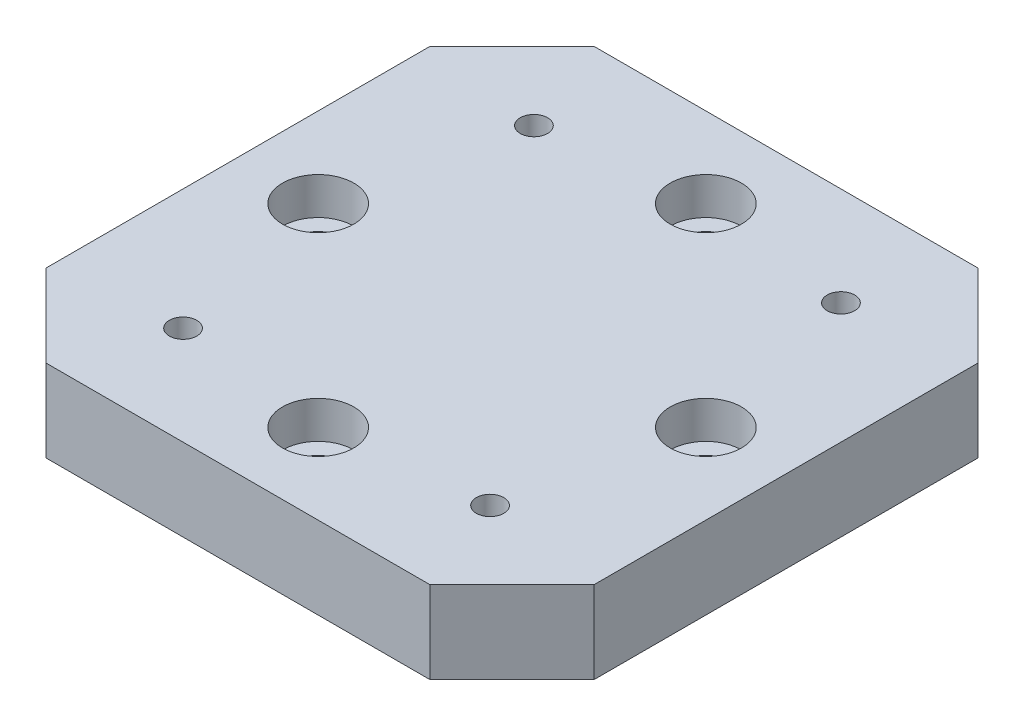
from build123d import *

# Parameters (mm, degrees)
SKETCH1_W                                           = 50
SKETCH1_H                                           = 50
BOSS_EXTRUDE1_DEPTH                                 = 7.5
M3_TAPPED_HOLE1_D                                   = 2.5
M3_TAPPED_HOLE1_DEPTH                               = 7.5
CBORE_FOR_M3_HEX_SOCKET_HEAD_CAP_SCREW1_D           = 3.4
CBORE_FOR_M3_HEX_SOCKET_HEAD_CAP_SCREW1_DEPTH       = 7.5
CBORE_FOR_M3_HEX_SOCKET_HEAD_CAP_SCREW1_CBORE_D     = 6.5
CBORE_FOR_M3_HEX_SOCKET_HEAD_CAP_SCREW1_CBORE_DEPTH = 3.4
CHAMFER1_SIZE                                       = 7.5


with BuildPart() as part:
    # Sketch1 → Boss-Extrude1 (new body)
    with BuildSketch(Plane(origin=(0, 0, 0), x_dir=(1, 0, 0), z_dir=(0, 1, 0))):
        Rectangle(SKETCH1_W, SKETCH1_H)
    extrude(amount=BOSS_EXTRUDE1_DEPTH)

    # M3 Tapped Hole1
    with Locations(Plane(origin=(0, 7.5, 0), x_dir=(1, 0, 0), z_dir=(0, 1, 0))):
        with Locations((-14, -16), (-14, 16), (14, 16), (14, -16)):
            Hole(M3_TAPPED_HOLE1_D / 2, depth=M3_TAPPED_HOLE1_DEPTH)

    # CBORE for M3 Hex Socket Head Cap Screw1
    with Locations(Plane(origin=(0, 7.5, 0), x_dir=(1, 0, 0), z_dir=(0, 1, 0))):
        with Locations((0, 17.67766953), (-17.67766953, 0), (17.67766953, 0), (0, -17.67766953)):
            CounterBoreHole(CBORE_FOR_M3_HEX_SOCKET_HEAD_CAP_SCREW1_D / 2, CBORE_FOR_M3_HEX_SOCKET_HEAD_CAP_SCREW1_CBORE_D / 2, CBORE_FOR_M3_HEX_SOCKET_HEAD_CAP_SCREW1_CBORE_DEPTH, depth=CBORE_FOR_M3_HEX_SOCKET_HEAD_CAP_SCREW1_DEPTH)

    # Chamfer1
    chamfer1_edges = [part.edges().sort_by_distance(p)[0] for p in [
        (25, 3.75, 25),
        (-25, 3.75, 25),
        (-25, 3.75, -25),
        (25, 3.75, -25),
    ]]
    chamfer(chamfer1_edges, length=CHAMFER1_SIZE)


solid = part.part
